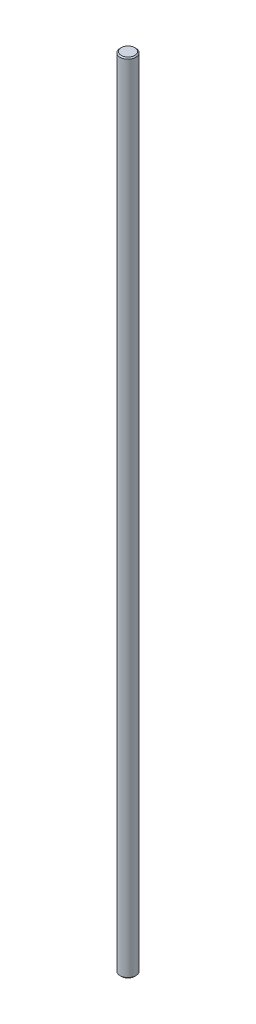
from build123d import *

# Parameters (mm, degrees)
ESQUISSE1_R             = 7
BOSS_EXTRU_1_DEPTH      = 710
CHANFREIN1_SIZE         = 1
ENL_V_START             = 1
ENL_V_MAT_EXTRU_1_DEPTH = 10


with BuildPart() as part:
    # Esquisse1 → Boss.-Extru.1 (new body)
    with BuildSketch(Plane(origin=(0, 0, 0), x_dir=(1, 0, 0), z_dir=(0, 1, 0))):
        with Locations(Location((0, 0, 0), (0, 0, 270))):  # turned: the seam where the file's is
            Circle(ESQUISSE1_R)
    extrude(amount=BOSS_EXTRU_1_DEPTH)

    # Chanfrein1
    chanfrein1_edges = [part.edges().sort_by_distance(p)[0] for p in [
        (0, 0, -7),
        (0, 710, -7),
    ]]
    chamfer(chanfrein1_edges, length=CHANFREIN1_SIZE)

    # Esquisse2 → Enlèv. mat.-Extru.1 (cut)
    with BuildSketch(Plane.XY.offset(ENL_V_START)):
        with BuildLine():
            Line((-4, 473), (-4, 236))
            ThreePointArc((-4, 236), (0, 232), (4, 236))
            Line((4, 236), (4, 473))
            ThreePointArc((4, 473), (0, 477), (-4, 473))
        make_face()
    extrude(amount=-ENL_V_MAT_EXTRU_1_DEPTH, mode=Mode.SUBTRACT)


solid = part.part
